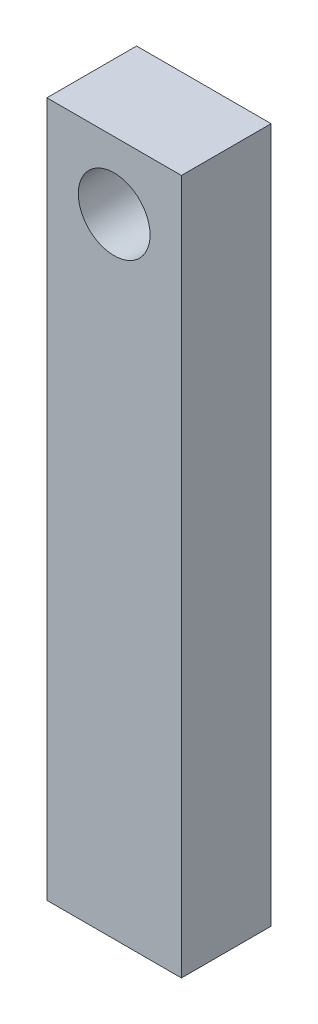
from build123d import *

# Parameters (mm, degrees)
SKETCH_1_W      = 15
SKETCH_1_H      = 77.5
SKETCH_1_R      = 4
EXTRUDE_1_DEPTH = 10


with BuildPart() as part:
    # 草圖1 → 填料-伸長1 (new body)
    with BuildSketch(Plane.XY):
        Rectangle(SKETCH_1_W, SKETCH_1_H)
        with Locations((0, 31.25)):
            Circle(SKETCH_1_R, mode=Mode.SUBTRACT)
    extrude(amount=EXTRUDE_1_DEPTH)


solid = part.part
